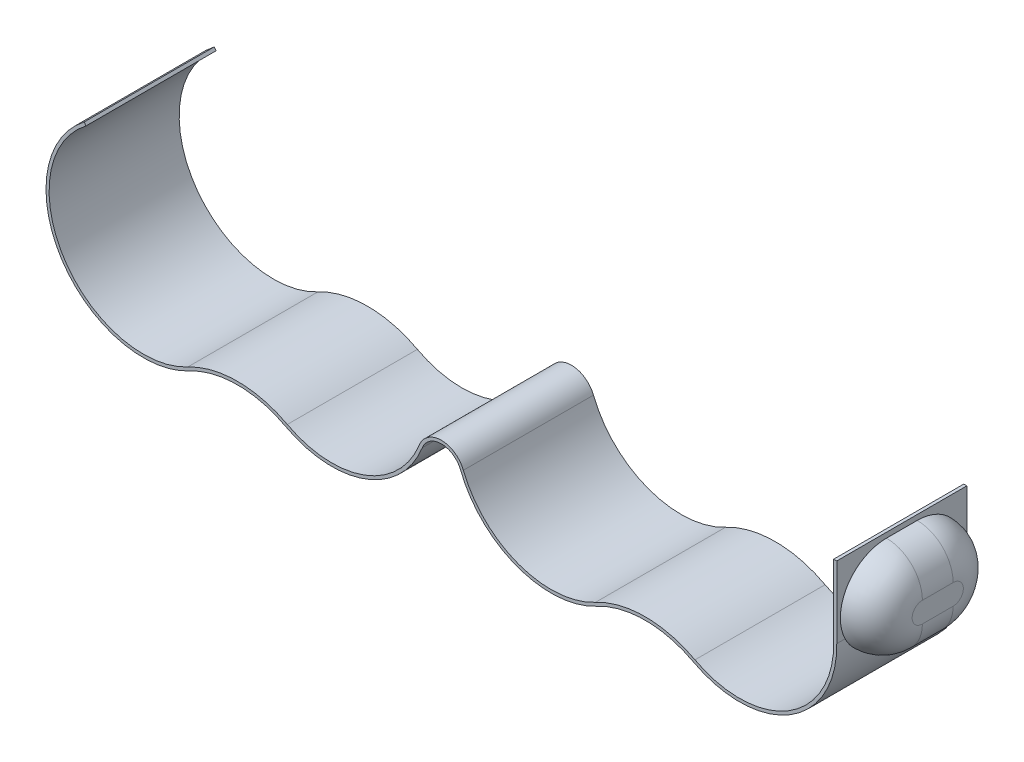
from build123d import *

# Parameters (mm, degrees)
BOSS_EXTRUDE1_DEPTH = 6.35
BOSS_EXTRUDE3_START = -0.288785
BOSS_EXTRUDE3_DEPTH = 3.798785
FILLET2_R           = 3.5


with BuildPart() as part:
    # Sketch2 → Boss-Extrude1 (new body, symmetric)
    with BuildSketch(Plane.XY):
        with BuildLine():
            Line((-34.874721139, 19.043380924), (-34.692361524, 18.805168895))
            ThreePointArc((-34.692361524, 18.805168895), (-37.96654895, 13.954446928), (-37.652863155, 8.110526316))
            ThreePointArc((-37.652863155, 8.110526316), (-32.263995686, 2.861184613), (-24.759487179, 3.388283261))
            ThreePointArc((-24.759487179, 3.388283261), (-19.9, 4.606687347), (-15.040512821, 3.388283261))
            ThreePointArc((-15.040512821, 3.388283261), (-7.536004314, 2.861184613), (-2.147136845, 8.110526316))
            ThreePointArc((-2.147136845, 8.110526316), (0, 9.569218559), (2.147136845, 8.110526316))
            ThreePointArc((2.147136845, 8.110526316), (7.536004314, 2.861184613), (15.040512821, 3.388283261))
            ThreePointArc((15.040512821, 3.388283261), (19.9, 4.606687347), (24.759487179, 3.388283261))
            ThreePointArc((24.759487179, 3.388283261), (33.900299187, 3.651616235), (38.298445746, 11.669103077))
            Line((38.298445746, 11.669103077), (38.298445746, 18.669103077))
            Line((38.298445746, 18.669103077), (38.598395064, 18.669103077))
            Line((38.598395064, 18.669103077), (38.598395064, 11.674617307))
            ThreePointArc((38.598395064, 11.674617307), (34.056830682, 3.395690678), (24.617948718, 3.123770759))
            ThreePointArc((24.617948718, 3.123770759), (19.9, 4.306687347), (15.182051282, 3.123770759))
            ThreePointArc((15.182051282, 3.123770759), (7.432830541, 2.579484111), (1.868239134, 8))
            ThreePointArc((1.868239134, 8), (0, 9.269218559), (-1.868239134, 8))
            ThreePointArc((-1.868239134, 8), (-7.432830541, 2.579484111), (-15.182051282, 3.123770759))
            ThreePointArc((-15.182051282, 3.123770759), (-19.9, 4.306687347), (-24.617948718, 3.123770759))
            ThreePointArc((-24.617948718, 3.123770759), (-32.367169459, 2.579484111), (-37.931760866, 8))
            ThreePointArc((-37.931760866, 8), (-38.255675546, 14.034483241), (-34.874721139, 19.043380924))
        make_face()
    extrude(amount=BOSS_EXTRUDE1_DEPTH, both=True)

    # Sketch6 → Boss-Extrude3 (add)
    with BuildSketch(Plane(origin=(38.598395064, 16.11055993, 0), x_dir=(0, 0, -1), z_dir=(1, 0, 0)).offset(BOSS_EXTRUDE3_START)):
        with BuildLine():
            Line((-1.5, 2.058543147), (1.5, 2.058543147))
            ThreePointArc((1.5, 2.058543147), (6, -2.441456853), (1.5, -6.941456853))
            Line((1.5, -6.941456853), (-1.5, -6.941456853))
            ThreePointArc((-1.5, -6.941456853), (-6, -2.441456853), (-1.5, 2.058543147))
        make_face()
    extrude(amount=BOSS_EXTRUDE3_DEPTH)

    # Fillet2
    fillet2_edges = [part.edges().sort_by_distance(p)[0] for p in [
        (42.108395064, 13.669103077, 6),
        (42.108395064, 9.169103077, 0),
        (42.108395064, 13.669103077, -6),
        (42.108395064, 18.169103077, 0),
    ]]
    fillet(fillet2_edges, radius=FILLET2_R)


solid = part.part
